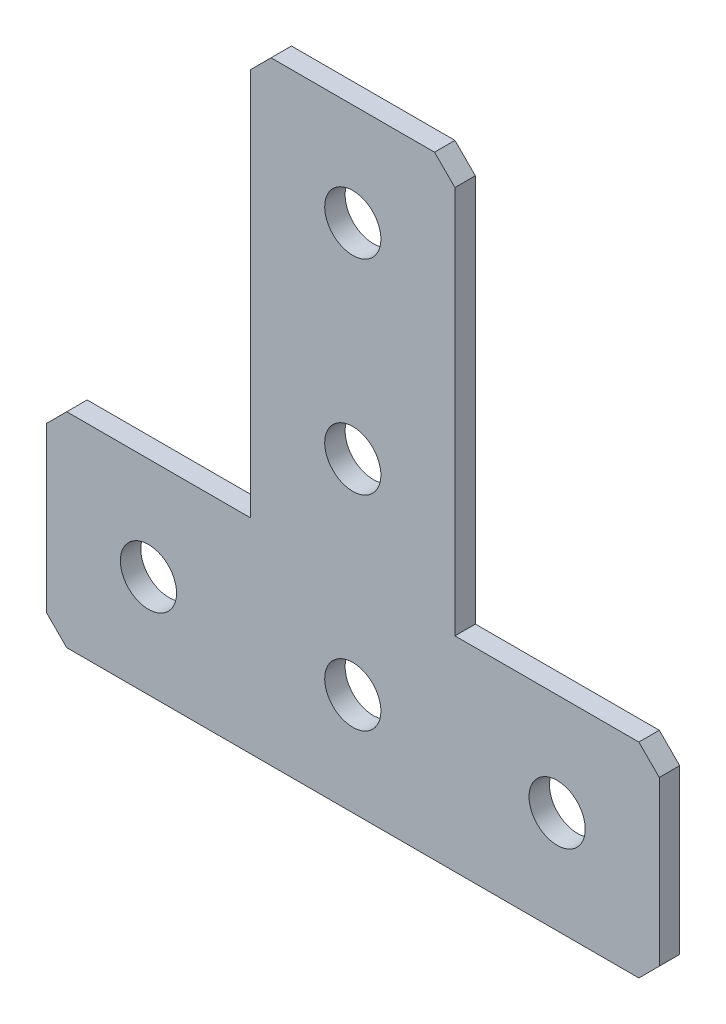
from build123d import *

# Parameters (mm, degrees)
EXTRUDE_1_DEPTH   = 2
HOLE_WIZARD_M51_D = 5.5
CHAMFER_1_SIZE    = 2


with BuildPart() as part:
    # Эскиз1 → Бобышка-Вытянуть1 (new body)
    with BuildSketch(Plane(origin=(0, 0, 0), x_dir=(1, 0, 0), z_dir=(0, 0, -1))):
        Polygon((-30, 60), (30, 60), (30, 40), (10, 40), (10, 0), (-10, 0), (-10, 40), (-30, 40), align=None)
    extrude(amount=EXTRUDE_1_DEPTH)

    # Отверстие с зазором M51 (through all)
    with Locations(Plane(origin=(0, 0, -2), x_dir=(1, 0, 0), z_dir=(0, 0, -1))):
        with Locations((0, 10), (0, 50), (-20, 50), (20, 50), (0, 30)):
            Hole(HOLE_WIZARD_M51_D / 2)

    # Фаска1
    chamfer_1_edges = [part.edges().sort_by_distance(p)[0] for p in [
        (-30, -40, -1),
        (-30, -60, -1),
        (30, -60, -1),
        (30, -40, -1),
        (10, 0, -1),
        (-10, 0, -1),
    ]]
    chamfer(chamfer_1_edges, length=CHAMFER_1_SIZE)


solid = part.part
